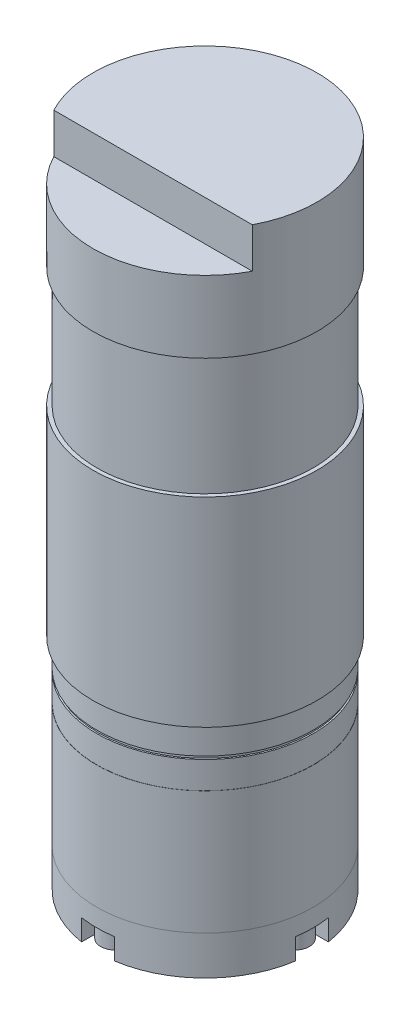
from build123d import *

# Parameters (mm, degrees)
SKETCH1_R           = 18
BOSS_EXTRUDE1_DEPTH = 89.8
SKETCH2_R           = 18.65
BOSS_EXTRUDE2_DEPTH = 18.65
BOSS_EXTRUDE4_DEPTH = 1.3
SKETCH3_R           = 18.65
BOSS_EXTRUDE3_DEPTH = 33.2
SKETCH11_R          = 4
CUT_EXTRUDE1_DEPTH  = 10.3
CUT_EXTRUDE2_DEPTH  = 6.7
SKETCH14_R          = 1.5
CUT_EXTRUDE3_DEPTH  = 10
SKETCH16_R          = 18.025
BOSS_EXTRUDE5_DEPTH = 20.5
SKETCH17_R          = 19.645678417
SKETCH17_R_2        = 17.75
CUT_EXTRUDE5_DEPTH  = 0.5
CUT_EXTRUDE6_DEPTH  = 3.5
SKETCH19_R          = 2.375
BOSS_EXTRUDE6_DEPTH = 3
CUT_EXTRUDE7_DEPTH  = 3


with BuildPart() as part:
    # Sketch1 → Boss-Extrude1 (new body)
    with BuildSketch(Plane(origin=(0, 0, 0), x_dir=(1, 0, 0), z_dir=(0, 1, 0))):
        Circle(SKETCH1_R)
    extrude(amount=BOSS_EXTRUDE1_DEPTH)

    # Sketch2 → Boss-Extrude2 (add)
    with BuildSketch(Plane(origin=(0, 89.8, 0), x_dir=(1, 0, 0), z_dir=(0, 1, 0))):
        Circle(SKETCH2_R)
    extrude(amount=BOSS_EXTRUDE2_DEPTH)

    # Sketch9 → Boss-Extrude4 (add)
    with BuildSketch(Plane.XZ):
        with BuildLine():
            Line((4.582575695, -10), (-4.582575695, -10))
            ThreePointArc((-4.582575695, -10), (-11, 0), (-4.582575695, 10))
            Line((-4.582575695, 10), (4.582575695, 10))
            ThreePointArc((4.582575695, 10), (11, 0), (4.582575695, -10))
        make_face()
    extrude(amount=BOSS_EXTRUDE4_DEPTH)

    # Sketch3 → Boss-Extrude3 (add)
    with BuildSketch(Plane(origin=(0, 69.8, 0), x_dir=(-1, 0, 0), z_dir=(0, -1, 0))):
        Circle(SKETCH3_R)
    extrude(amount=BOSS_EXTRUDE3_DEPTH)

    # Sketch11 → Cut-Extrude1 (cut)
    with BuildSketch(Plane.XZ.offset(1.3)):
        Circle(SKETCH11_R)
    extrude(amount=-CUT_EXTRUDE1_DEPTH, mode=Mode.SUBTRACT)

    # Sketch13 → Cut-Extrude2 (cut)
    with BuildSketch(Plane(origin=(0, 108.45, 0), x_dir=(1, 0, 0), z_dir=(0, 1, 0))):
        with BuildLine():
            Line((-16.522711642, -8.65), (16.522711642, -8.65))
            ThreePointArc((16.522711642, -8.65), (0, -18.65), (-16.522711642, -8.65))
        make_face()
    extrude(amount=-CUT_EXTRUDE2_DEPTH, mode=Mode.SUBTRACT)

    # Sketch14 → Cut-Extrude3 (cut)
    with BuildSketch(Plane.XZ):
        with Locations((-9.899494937, 9.899494937)):
            Circle(SKETCH14_R)
        with Locations((9.899494937, 9.899494937)):
            Circle(SKETCH14_R)
        with Locations((9.899494937, -9.899494937)):
            Circle(SKETCH14_R)
        with Locations((-9.899494937, -9.899494937)):
            Circle(SKETCH14_R)
    extrude(amount=-CUT_EXTRUDE3_DEPTH, mode=Mode.SUBTRACT)

    # Sketch16 → Boss-Extrude5 (add)
    with BuildSketch(Plane(origin=(0, 6.5, 0), x_dir=(-1, 0, 0), z_dir=(0, -1, 0))):
        Circle(SKETCH16_R)
    extrude(amount=-BOSS_EXTRUDE5_DEPTH)

    # Sketch17 → Cut-Extrude5 (cut)
    with BuildSketch(Plane(origin=(0, 31.5, 0), x_dir=(-1, 0, 0), z_dir=(0, -1, 0))):
        Circle(SKETCH17_R)
        Circle(SKETCH17_R_2, mode=Mode.SUBTRACT)
    extrude(amount=-CUT_EXTRUDE5_DEPTH, mode=Mode.SUBTRACT)

    # Sketch18 → Cut-Extrude6 (cut)
    with BuildSketch(Plane.XZ):
        with BuildLine():
            Line((2.75, -15), (2.75, -20))
            Line((2.75, -20), (-2.75, -20))
            Line((-2.75, -20), (-2.75, -15))
            ThreePointArc((-2.75, -15), (0, -12.25), (2.75, -15))
        make_face()
        with BuildLine():
            Line((2.75, 15), (2.75, 20))
            Line((2.75, 20), (-2.75, 20))
            Line((-2.75, 20), (-2.75, 15))
            ThreePointArc((-2.75, 15), (0, 12.25), (2.75, 15))
        make_face()
        with BuildLine():
            Line((-15, 2.75), (-20, 2.75))
            Line((-20, 2.75), (-20, -2.75))
            Line((-20, -2.75), (-15, -2.75))
            ThreePointArc((-15, -2.75), (-12.25, 0), (-15, 2.75))
        make_face()
        with BuildLine():
            Line((15, -2.75), (20, -2.75))
            Line((20, -2.75), (20, 2.75))
            Line((20, 2.75), (15, 2.75))
            ThreePointArc((15, 2.75), (12.25, 0), (15, -2.75))
        make_face()
    extrude(amount=-CUT_EXTRUDE6_DEPTH, mode=Mode.SUBTRACT)

    # Sketch19 → Boss-Extrude6 (add)
    with BuildSketch(Plane.XZ.offset(-3.5)):
        with Locations((-15, 0)):
            Circle(SKETCH19_R)
        with Locations((0, 15)):
            Circle(SKETCH19_R)
        with Locations((15, 0)):
            Circle(SKETCH19_R)
        with Locations((0, -15)):
            Circle(SKETCH19_R)
    extrude(amount=BOSS_EXTRUDE6_DEPTH)

    # Sketch20 → Cut-Extrude7 (cut)
    with BuildSketch(Plane.XZ.offset(-0.5)):
        Polygon((16.515813069, 0.875155083), (15, 1.750310167), (13.484186931, 0.875155083), (13.484186931, -0.875155083), (15, -1.750310167), (16.515813069, -0.875155083), align=None)
        Polygon((-1.750310167, 15), (-0.875155083, 13.484186931), (0.875155083, 13.484186931), (1.750310167, 15), (0.875155083, 16.515813069), (-0.875155083, 16.515813069), align=None)
        Polygon((0.875155083, -16.515813069), (1.750310167, -15), (0.875155083, -13.484186931), (-0.875155083, -13.484186931), (-1.750310167, -15), (-0.875155083, -16.515813069), align=None)
        Polygon((-16.515813069, -0.875155083), (-15, -1.750310167), (-13.484186931, -0.875155083), (-13.484186931, 0.875155083), (-15, 1.750310167), (-16.515813069, 0.875155083), align=None)
    extrude(amount=-CUT_EXTRUDE7_DEPTH, mode=Mode.SUBTRACT)


solid = part.part
